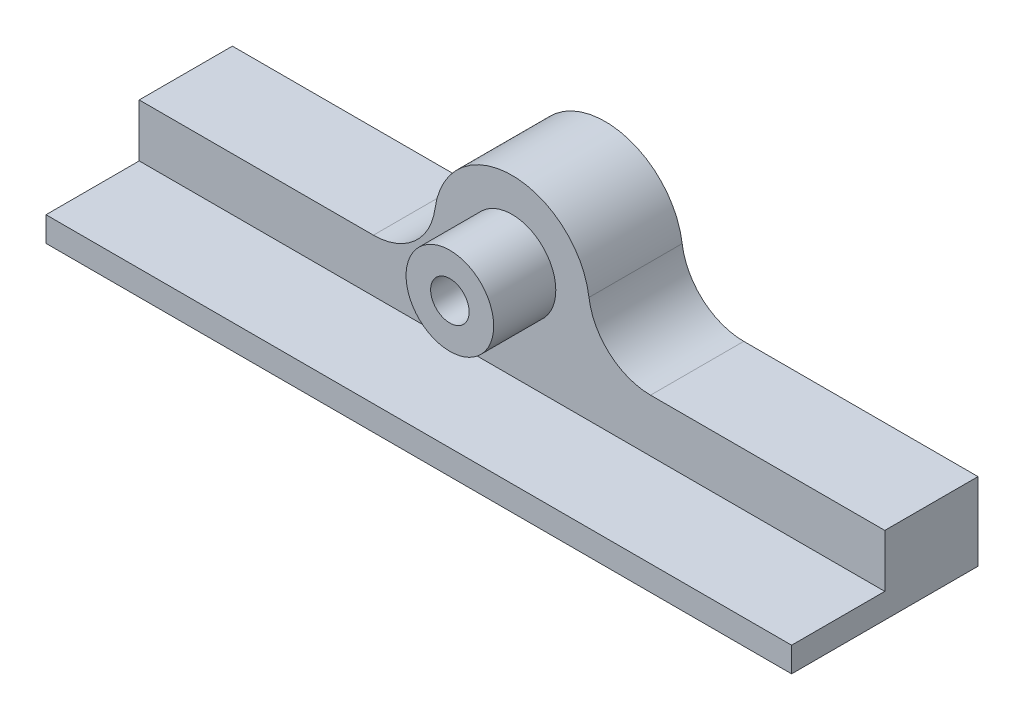
from build123d import *

# Parameters (mm, degrees)
BOSS_EXTRUDE1_DEPTH = 10
BOSS_EXTRUDE2_DEPTH = 15
FILLET1_R           = 10
SKETCH3_W           = 120
SKETCH3_H           = 4
BOSS_EXTRUDE3_DEPTH = 15


with BuildPart() as part:
    # Sketch1 → Boss-Extrude1 (new body)
    with BuildSketch(Plane.XY):
        with BuildLine():
            ThreePointArc((-4.079215611, 5.75), (0, 7.05), (4.079215611, 5.75))
            Line((4.079215611, 5.75), (-4.079215611, 5.75))
        make_face()
        with BuildLine():
            Line((-4.079215611, 5.75), (4.079215611, 5.75))
            ThreePointArc((4.079215611, 5.75), (0, -7.05), (-4.079215611, 5.75))
        make_face()
        with BuildLine():
            ThreePointArc((-2.554236133, 1.756666667), (0, -3.1), (2.554236133, 1.756666667))
            ThreePointArc((2.554236133, 1.756666667), (0, 3.1), (-2.554236133, 1.756666667))
        make_face(mode=Mode.SUBTRACT)
    extrude(amount=BOSS_EXTRUDE1_DEPTH)

    # Sketch2 → Boss-Extrude2 (add)
    with BuildSketch(Plane(origin=(0, 0, 0), x_dir=(-1, 0, 0), z_dir=(0, 0, -1))):
        with BuildLine():
            Line((-60, -19.5), (60, -19.5))
            Line((60, -19.5), (60, -7))
            Line((60, -7), (12.5, -7))
            Line((12.5, -7), (12.5, 0))
            ThreePointArc((12.5, 0), (0, 12.5), (-12.5, 0))
            Line((-12.5, 0), (-12.5, -7))
            Line((-12.5, -7), (-60, -7))
            Line((-60, -7), (-60, -19.5))
        make_face()
    extrude(amount=BOSS_EXTRUDE2_DEPTH)

    # Fillet1
    fillet1_edges = [part.edges().sort_by_distance(p)[0] for p in [
        (-12.5, -7, -7.5),
        (12.5, -7, -7.5),
    ]]
    fillet(fillet1_edges, radius=FILLET1_R)

    # Sketch3 → Boss-Extrude3 (add)
    with BuildSketch(Plane.XY):
        with Locations((0, -17.5)):
            Rectangle(SKETCH3_W, SKETCH3_H)
    extrude(amount=BOSS_EXTRUDE3_DEPTH)


solid = part.part
